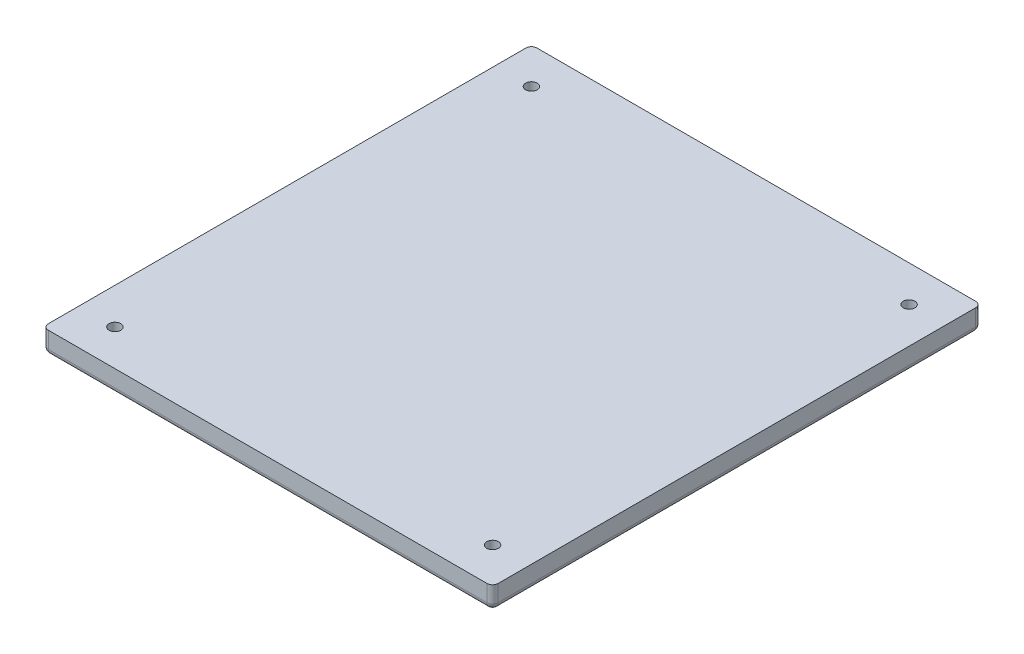
from build123d import *

# Parameters (mm, degrees)
SKETCH1_W           = 81
SKETCH1_H           = 88
BOSS_EXTRUDE1_DEPTH = 4
SKETCH3_R           = 1.05
CUT_EXTRUDE1_DEPTH  = 10
FILLET1_R           = 1


with BuildPart() as part:
    # Sketch1 → Boss-Extrude1 (new body)
    with BuildSketch(Plane(origin=(0, 0, 0), x_dir=(1, 0, 0), z_dir=(0, 1, 0))):
        with Locations((40.5, 44)):
            Rectangle(SKETCH1_W, SKETCH1_H)
    extrude(amount=BOSS_EXTRUDE1_DEPTH)

    # Sketch3 → Cut-Extrude1 (cut)
    with BuildSketch(Plane(origin=(0, 4, 0), x_dir=(1, 0, 0), z_dir=(0, 1, 0))):
        with Locations((6.5, 81.5)):
            Circle(SKETCH3_R)
        with Locations((74.5, 81.5)):
            Circle(SKETCH3_R)
        with Locations((74.5, 6.5)):
            Circle(SKETCH3_R)
        with Locations((6.5, 6.5)):
            Circle(SKETCH3_R)
    extrude(amount=-CUT_EXTRUDE1_DEPTH, mode=Mode.SUBTRACT)

    # Fillet1
    fillet1_edges = [part.edges().sort_by_distance(p)[0] for p in [
        (40.5, 0, -88),
        (81, 0, -44),
        (40.5, 0, 0),
        (0, 0, -44),
        (0, 2, -88),
        (81, 2, -88),
        (81, 2, 0),
        (0, 2, 0),
    ]]
    fillet(fillet1_edges, radius=FILLET1_R)


solid = part.part
